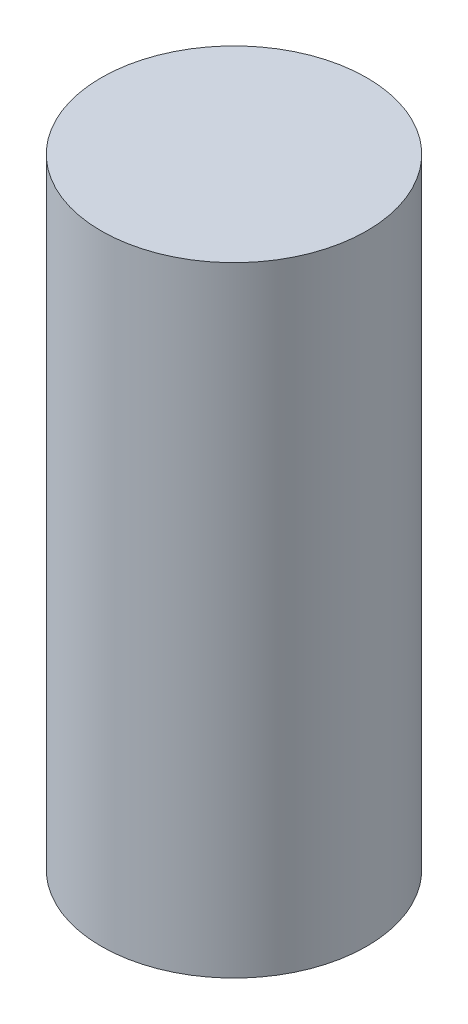
from build123d import *

# Parameters (mm, degrees)
SKETCH1_R           = 1.5
BOSS_EXTRUDE1_DEPTH = 7


with BuildPart() as part:
    # Sketch1 → Boss-Extrude1 (new body)
    with BuildSketch(Plane(origin=(0, 0, 0), x_dir=(1, 0, 0), z_dir=(0, 1, 0))):
        with Locations(Location((0, 0, 0), (0, 0, 270))):  # turned: the seam where the file's is
            Circle(SKETCH1_R)
    extrude(amount=BOSS_EXTRUDE1_DEPTH)


solid = part.part
